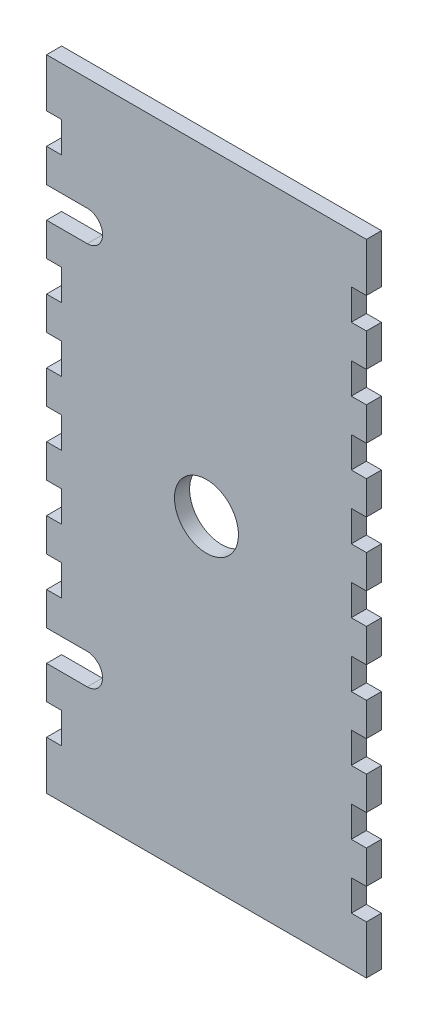
from build123d import *

# Parameters (mm, degrees)
SKETCH1_R           = 6.35
BOSS_EXTRUDE2_DEPTH = 2.9972


with BuildPart() as part:
    # Sketch1 → Boss-Extrude2 (new body)
    with BuildSketch(Plane.XY):
        with BuildLine():
            Line((0, 0), (0, -9.652))
            Line((0, -9.652), (2.9972, -9.652))
            Line((2.9972, -9.652), (2.9972, -15.748))
            Line((2.9972, -15.748), (0, -15.748))
            Line((0, -15.748), (0, -22.352))
            Line((0, -22.352), (2.9972, -22.352))
            Line((2.9972, -22.352), (8.0772, -22.352))
            ThreePointArc((8.0772, -22.352), (11.1252, -25.4), (8.0772, -28.448))
            Line((8.0772, -28.448), (2.9972, -28.448))
            Line((2.9972, -28.448), (0, -28.448))
            Line((0, -28.448), (0, -35.052))
            Line((0, -35.052), (2.9972, -35.052))
            Line((2.9972, -35.052), (2.9972, -41.148))
            Line((2.9972, -41.148), (0, -41.148))
            Line((0, -41.148), (0, -47.752))
            Line((0, -47.752), (2.9972, -47.752))
            Line((2.9972, -47.752), (2.9972, -53.848))
            Line((2.9972, -53.848), (0, -53.848))
            Line((0, -53.848), (0, -60.452))
            Line((0, -60.452), (2.9972, -60.452))
            Line((2.9972, -60.452), (2.9972, -66.548))
            Line((2.9972, -66.548), (0, -66.548))
            Line((0, -66.548), (0, -73.152))
            Line((0, -73.152), (2.9972, -73.152))
            Line((2.9972, -73.152), (2.9972, -79.248))
            Line((2.9972, -79.248), (0, -79.248))
            Line((0, -79.248), (0, -85.852))
            Line((0, -85.852), (2.9972, -85.852))
            Line((2.9972, -85.852), (2.9972, -91.948))
            Line((2.9972, -91.948), (0, -91.948))
            Line((0, -91.948), (0, -98.552))
            Line((0, -98.552), (2.9972, -98.552))
            Line((2.9972, -98.552), (8.0772, -98.552))
            ThreePointArc((8.0772, -98.552), (11.1252, -101.6), (8.0772, -104.648))
            Line((8.0772, -104.648), (2.9972, -104.648))
            Line((2.9972, -104.648), (0, -104.648))
            Line((0, -104.648), (0, -111.252))
            Line((0, -111.252), (2.9972, -111.252))
            Line((2.9972, -111.252), (2.9972, -117.348))
            Line((2.9972, -117.348), (0, -117.348))
            Line((0, -117.348), (0, -127))
            Line((0, -127), (63.5, -127))
            Line((63.5, -127), (63.5, -117.348))
            Line((63.5, -117.348), (60.5028, -117.348))
            Line((60.5028, -117.348), (60.5028, -111.252))
            Line((60.5028, -111.252), (63.5, -111.252))
            Line((63.5, -111.252), (63.5, -104.648))
            Line((63.5, -104.648), (60.5028, -104.648))
            Line((60.5028, -104.648), (60.5028, -98.552))
            Line((60.5028, -98.552), (63.5, -98.552))
            Line((63.5, -98.552), (63.5, -91.948))
            Line((63.5, -91.948), (60.5028, -91.948))
            Line((60.5028, -91.948), (60.5028, -85.852))
            Line((60.5028, -85.852), (63.5, -85.852))
            Line((63.5, -85.852), (63.5, -79.248))
            Line((63.5, -79.248), (60.5028, -79.248))
            Line((60.5028, -79.248), (60.5028, -73.152))
            Line((60.5028, -73.152), (63.5, -73.152))
            Line((63.5, -73.152), (63.5, -66.548))
            Line((63.5, -66.548), (60.5028, -66.548))
            Line((60.5028, -66.548), (60.5028, -60.452))
            Line((60.5028, -60.452), (63.5, -60.452))
            Line((63.5, -60.452), (63.5, -53.848))
            Line((63.5, -53.848), (60.5028, -53.848))
            Line((60.5028, -53.848), (60.5028, -47.752))
            Line((60.5028, -47.752), (63.5, -47.752))
            Line((63.5, -47.752), (63.5, -41.148))
            Line((63.5, -41.148), (60.5028, -41.148))
            Line((60.5028, -41.148), (60.5028, -35.052))
            Line((60.5028, -35.052), (63.5, -35.052))
            Line((63.5, -35.052), (63.5, -28.448))
            Line((63.5, -28.448), (60.5028, -28.448))
            Line((60.5028, -28.448), (60.5028, -22.352))
            Line((60.5028, -22.352), (63.5, -22.352))
            Line((63.5, -22.352), (63.5, -15.748))
            Line((63.5, -15.748), (60.5028, -15.748))
            Line((60.5028, -15.748), (60.5028, -9.652))
            Line((60.5028, -9.652), (63.5, -9.652))
            Line((63.5, -9.652), (63.5, 0))
            Line((63.5, 0), (0, 0))
        make_face()
        with Locations((31.75, -63.5)):
            Circle(SKETCH1_R, mode=Mode.SUBTRACT)
    extrude(amount=BOSS_EXTRUDE2_DEPTH)


solid = part.part
